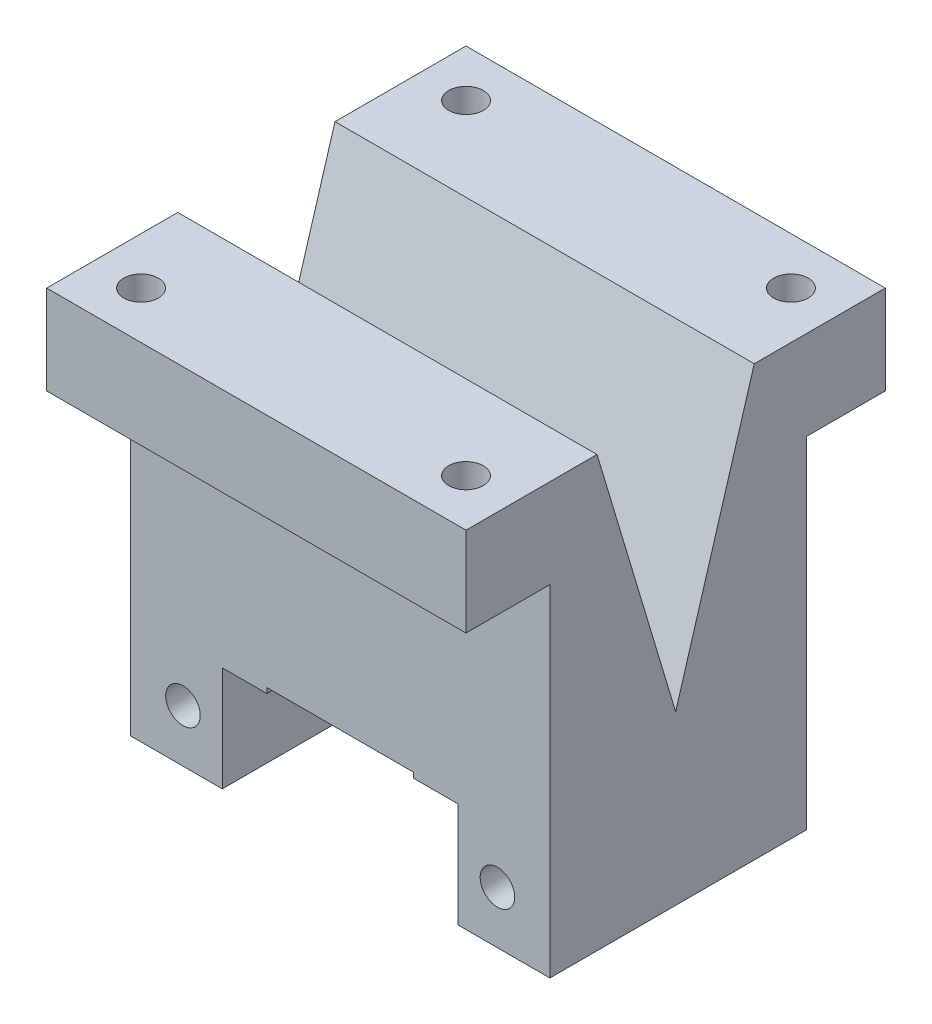
from build123d import *

# Parameters (mm, degrees)
SKETCH1_W             = 40
SKETCH1_H             = 40
BOSS_EXTRUDE1_DEPTH   = 41
M4X0_7_TAPPED_HOLE1_D = 3.3
SKETCH11_W            = 11.25
SKETCH11_H            = 7
CUT_EXTRUDE5_REACH    = 43
SKETCH12_R            = 10
M4X0_7_TAPPED_HOLE2_D = 3.3
SKETCH15_W            = 40
SKETCH15_H            = 7.5
CUT_EXTRUDE6_DEPTH    = 32.5
SKETCH16_W            = 22.5
SKETCH16_H            = 7
CUT_EXTRUDE7_DEPTH    = 21
CUT_EXTRUDE8_REACH    = 43
SKETCH17_W            = 22.5
SKETCH17_H            = 12.5
CUT_EXTRUDE9_DEPTH    = 2
CUT_EXTRUDE10_DEPTH   = 41
SKETCH20_W            = 22.5
SKETCH20_H            = 10
CUT_EXTRUDE11_DEPTH   = 12.5
SKETCH21_W            = 0.5
SKETCH21_H            = 32.5
CUT_EXTRUDE12_DEPTH   = 41


with BuildPart() as part:
    # Sketch1 → Boss-Extrude1 (new body)
    with BuildSketch(Plane(origin=(0, 0, 0), x_dir=(1, 0, 0), z_dir=(0, 1, 0))):
        Rectangle(SKETCH1_W, SKETCH1_H)
    extrude(amount=-BOSS_EXTRUDE1_DEPTH)

    # M4x0.7 Tapped Hole1 (through all)
    with Locations(Plane(origin=(0, 0, 0), x_dir=(1, 0, 0), z_dir=(0, 1, 0))):
        with Locations((-15.5, 15.5), (15.5, 15.5), (15.5, -15.5), (-15.5, -15.5)):
            Hole(M4X0_7_TAPPED_HOLE1_D / 2)

    # Sketch11 → Cut-Revolve2 (revolve, cut)
    with BuildSketch(Plane.XY):
        with Locations((5.625, -36)):
            Rectangle(SKETCH11_W, SKETCH11_H)
    revolve(axis=Axis((0, 0, 0), (0, -1, 0)), mode=Mode.SUBTRACT)

    # Sketch12 → Cut-Extrude5 (cut, up to next)
    with BuildSketch(Plane.XZ.offset(41), mode=Mode.PRIVATE) as cut_extrude5_sk1:
        Circle(SKETCH12_R)
    cut_extrude5_tool1 = extrude(cut_extrude5_sk1.sketch, amount=-CUT_EXTRUDE5_REACH, mode=Mode.PRIVATE) & part.part
    add(cut_extrude5_tool1.solids().sort_by_distance((0, -41, 0))[0], mode=Mode.SUBTRACT)

    # M4x0.7 Tapped Hole2 (through all)
    with Locations(Plane(origin=(0, 0, -20), x_dir=(-1, 0, 0), z_dir=(0, 0, -1))):
        with Locations((15, -36), (-15, -36)):
            Hole(M4X0_7_TAPPED_HOLE2_D / 2)

    # Sketch15 → Cut-Extrude6 (cut)
    with BuildSketch(Plane.XZ.offset(41)):
        with Locations((0, -16.25)):
            Rectangle(SKETCH15_W, SKETCH15_H)
        with Locations((0, 16.25)):
            Rectangle(SKETCH15_W, SKETCH15_H)
    extrude(amount=-CUT_EXTRUDE6_DEPTH, mode=Mode.SUBTRACT)

    # Sketch16 → Cut-Extrude7 (cut, through all)
    with BuildSketch(Plane.XY):
        with Locations((0, -36)):
            Rectangle(SKETCH16_W, SKETCH16_H)
    extrude(amount=CUT_EXTRUDE7_DEPTH, mode=Mode.SUBTRACT)

    # Sketch17 → Cut-Extrude8 (cut, up to next)
    with BuildSketch(Plane.XZ.offset(41), mode=Mode.PRIVATE) as cut_extrude8_sk1:
        with Locations((0, 6.25)):
            Rectangle(SKETCH17_W, SKETCH17_H)
    cut_extrude8_tool1 = extrude(cut_extrude8_sk1.sketch, amount=-CUT_EXTRUDE8_REACH, mode=Mode.PRIVATE) & part.part
    add(cut_extrude8_tool1.solids().sort_by_distance((0, -41, 6.25))[0], mode=Mode.SUBTRACT)

    # Sketch18 → Cut-Extrude9 (cut)
    with BuildSketch(Plane.XZ.offset(32.5)):
        with BuildLine():
            Line((-7, 0), (-7, 12.5))
            Line((-7, 12.5), (7, 12.5))
            Line((7, 12.5), (7, 0))
            ThreePointArc((7, 0), (0, -7), (-7, 0))
        make_face()
    extrude(amount=-CUT_EXTRUDE9_DEPTH, mode=Mode.SUBTRACT)

    # Sketch19 → Cut-Extrude10 (cut, through all)
    with BuildSketch(Plane.ZY.offset(20)):
        Polygon((0, -25), (7.5, 0), (-7.5, 0), align=None)
    extrude(amount=-CUT_EXTRUDE10_DEPTH, mode=Mode.SUBTRACT)

    # Sketch20 → Cut-Extrude11 (cut)
    with BuildSketch(Plane.XY.offset(12.5)):
        with Locations((0, -36)):
            Rectangle(SKETCH20_W, SKETCH20_H)
    extrude(amount=-CUT_EXTRUDE11_DEPTH, mode=Mode.SUBTRACT)

    # Sketch21 → Cut-Extrude12 (cut, through all)
    with BuildSketch(Plane.ZY.offset(20)):
        with Locations((12.25, -24.75)):
            Rectangle(SKETCH21_W, SKETCH21_H)
    extrude(amount=-CUT_EXTRUDE12_DEPTH, mode=Mode.SUBTRACT)


solid = part.part
